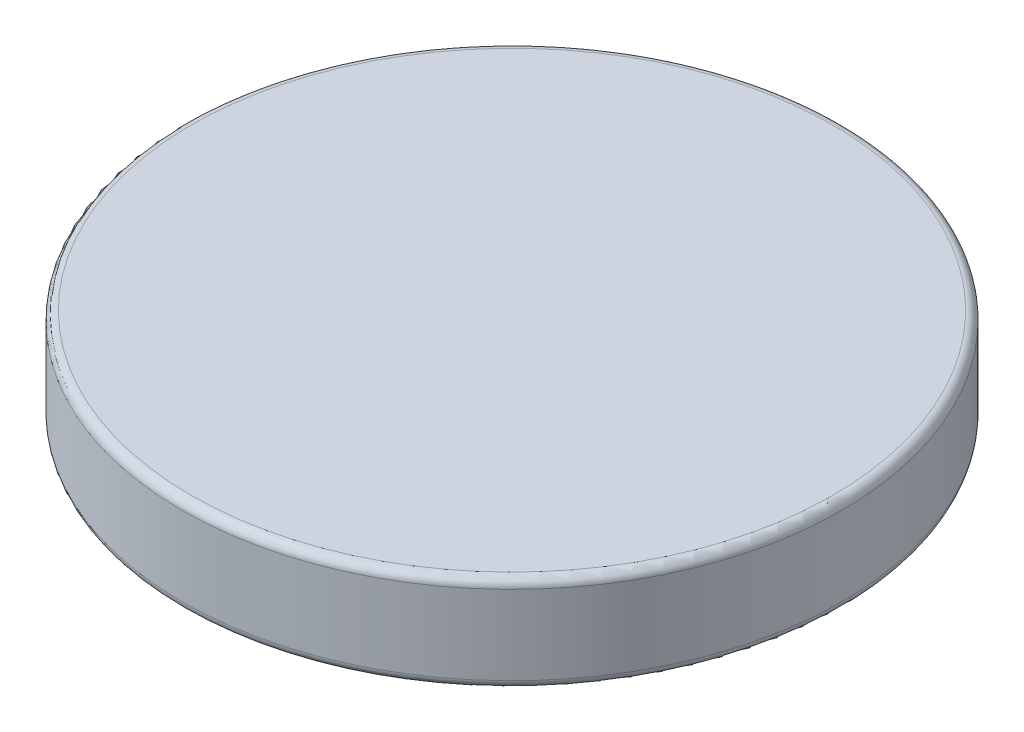
from build123d import *

# Parameters (mm, degrees)
PROFILE_R           = 3.75
CAP_DEPTH           = 1.1
PRODUCTION_FILLET_R = 0.1


with BuildPart() as part:
    # Profile → Cap (new body)
    with BuildSketch(Plane(origin=(0, 0, 0), x_dir=(1, 0, 0), z_dir=(0, 1, 0))):
        Circle(PROFILE_R)
    extrude(amount=CAP_DEPTH)

    # Production Fillet
    production_fillet_edges = [part.edges().sort_by_distance(p)[0] for p in [
        (-3.75, 0, 0),
        (-3.75, 1.1, 0),
    ]]
    fillet(production_fillet_edges, radius=PRODUCTION_FILLET_R)


solid = part.part
